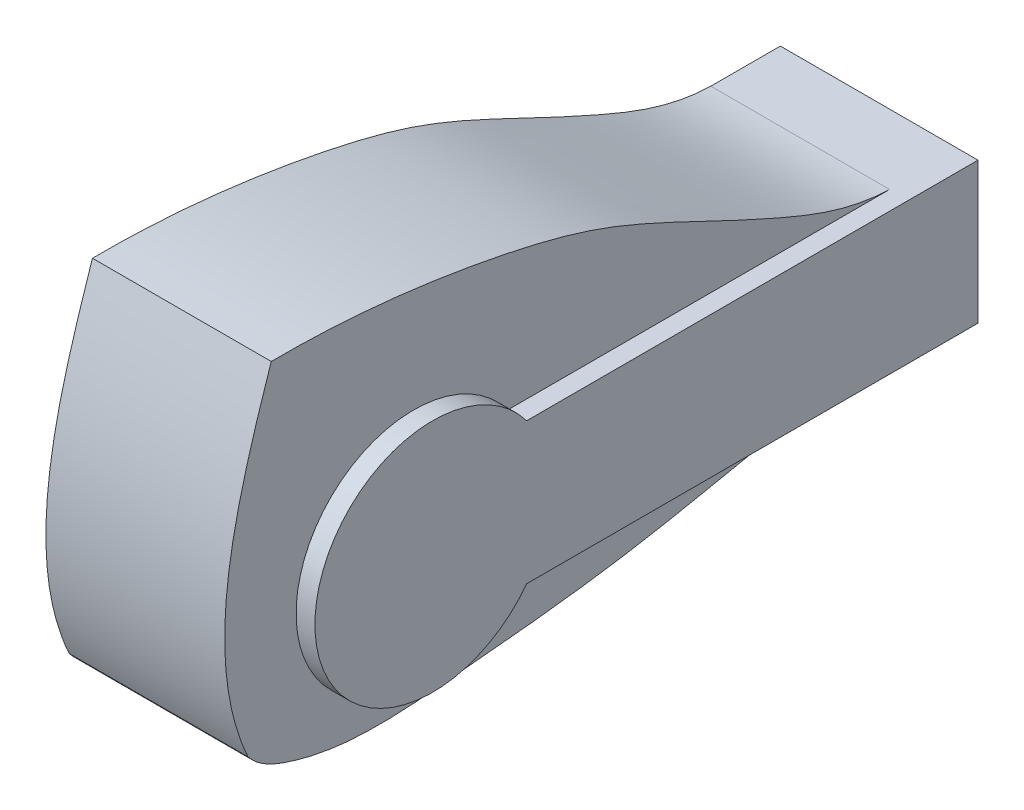
from build123d import *

# Parameters (mm, degrees)
BOSS_EXTRUDE1_DEPTH      = 19
BOSS_EXTRUDE1_DEPTH_BACK = 19
SKETCH4_R                = 25
BOSS_EXTRUDE2_DEPTH      = 4
SKETCH7_W                = 96.334868302
SKETCH7_H                = 30
BOSS_EXTRUDE4_DEPTH      = 4


with BuildPart() as part:
    # Sketch3 → Boss-Extrude1 (new, two sides: drawn at the far end of the back side and taken through both)
    with BuildSketch(Plane(origin=(0, 0, 0), x_dir=(0, 0, -1), z_dir=(1, 0, 0)).offset(-BOSS_EXTRUDE1_DEPTH_BACK)):
        with BuildLine():
            Line((101.125836247, 15), (115.903665145, 15))
            Line((115.903665145, 15), (115.903665145, -15))
            Line((115.903665145, -15), (101.125836247, -15))
            add(Edge.make_bspline(
                [(-35.228525995, -21.228719453), (-33.006450865, -24.07111779), (-26.49753273, -26.863412426), (-11.335277797, -30.129234604), (12.719064979, -27.929719806), (43.096683762, -25.057564772), (73.387051738, -18.43106409), (92.126866656, -14.867150153), (101.125836247, -15)],
                knots=[0, 0, 0, 0, 0.075207413, 0.148741353, 0.333288022, 0.588928464, 0.80810625, 1, 1, 1, 1], degree=3))
            add(Edge.make_bspline(
                [(-30.278821492, 49.042821653), (-37.712518178, 26.883259009), (-45.501408919, 1.573924427), (-35.228525995, -21.228719453)],
                knots=[0, 0, 0, 0, 1, 1, 1, 1], degree=3))
            add(Edge.make_bspline(
                [(-30.278821492, 49.042821653), (-14.032986644, 49.168084942), (9.286633448, 46.599377579), (40.599784556, 39.089257371), (60.084206577, 29.540337779), (80.216148289, 20.129950878), (93.055643568, 15.237102325), (101.125836247, 15)],
                knots=[0, 0, 0, 0, 0.354356982, 0.512751412, 0.701525574, 0.826928454, 1, 1, 1, 1], degree=3))
        make_face()
    extrude(amount=BOSS_EXTRUDE1_DEPTH + BOSS_EXTRUDE1_DEPTH_BACK)

    # Sketch4 → Boss-Extrude2 (add)
    with BuildSketch(Plane(origin=(19, 0, 0), x_dir=(0, 0, -1), z_dir=(1, 0, 0))):
        Circle(SKETCH4_R)
    extrude(amount=BOSS_EXTRUDE2_DEPTH)

    # Sketch7 → Boss-Extrude4 (add)
    with BuildSketch(Plane(origin=(19, 0, 0), x_dir=(0, 0, -1), z_dir=(1, 0, 0))):
        with Locations((67.736230994, 0)):
            Rectangle(SKETCH7_W, SKETCH7_H)
    extrude(amount=BOSS_EXTRUDE4_DEPTH)


solid = part.part
